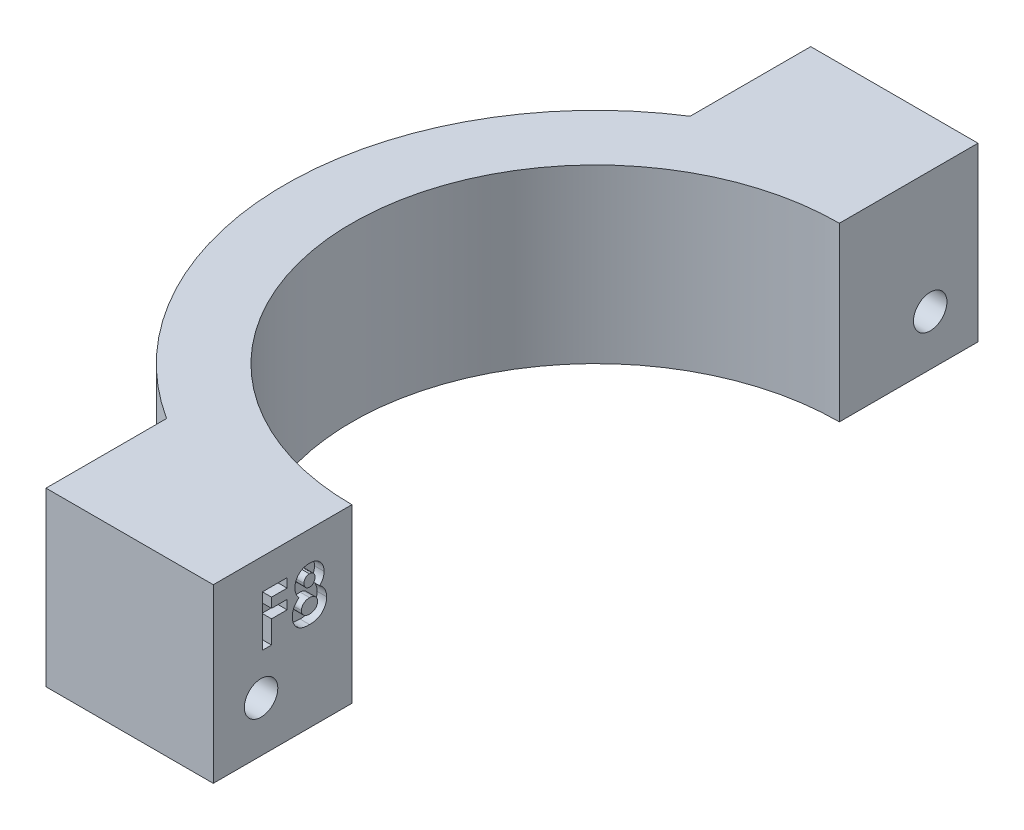
from build123d import *

# Parameters (mm, degrees)
BOSS_EXTRUDE1_DEPTH = 18
SKETCH2_R           = 1.75
CUT_EXTRUDE1_DEPTH  = 33.5
CUT_EXTRUDE2_DEPTH  = 1
CUT_EXTRUDE3_DEPTH  = 5


with BuildPart() as part:
    # Sketch1 → Boss-Extrude1 (new body)
    with BuildSketch(Plane(origin=(0, 0, 0), x_dir=(1, 0, 0), z_dir=(0, 1, 0))):
        with BuildLine():
            Line((-11.998275301, 32.528571429), (-29.498275301, 32.528571429))
            Line((-29.498275301, 32.528571429), (-29.498275301, 19.914699304))
            ThreePointArc((-29.498275301, 19.914699304), (-21.114218589, 23.723916882), (-11.998275301, 25.028571429))
            Line((-11.998275301, 25.028571429), (-11.998275301, 32.528571429))
        make_face()
        with BuildLine():
            ThreePointArc((-11.998275301, 25.028571429), (-21.114218589, 23.723916882), (-29.498275301, 19.914699304))
            ThreePointArc((-29.498275301, 19.914699304), (-44.498275301, -7.471428571), (-29.498275301, -34.857556447))
            ThreePointArc((-29.498275301, -34.857556447), (-21.114218589, -38.666774025), (-11.998275301, -39.971428571))
            Line((-11.998275301, -39.971428571), (-11.998275301, -32.971428571))
            ThreePointArc((-11.998275301, -32.971428571), (-37.498275301, -7.471428571), (-11.998275301, 18.028571429))
            Line((-11.998275301, 18.028571429), (-11.998275301, 25.028571429))
        make_face()
        with BuildLine():
            Line((-29.498275301, -34.857556447), (-29.498275301, -47.471428571))
            Line((-29.498275301, -47.471428571), (-11.998275301, -47.471428571))
            Line((-11.998275301, -47.471428571), (-11.998275301, -39.971428571))
            ThreePointArc((-11.998275301, -39.971428571), (-21.114218589, -38.666774025), (-29.498275301, -34.857556447))
        make_face()
    extrude(amount=BOSS_EXTRUDE1_DEPTH)

    # Sketch2 → Cut-Extrude1 (cut, through all)
    with BuildSketch(Plane(origin=(-11.998275301, 0, 0), x_dir=(0, 0, -1), z_dir=(1, 0, 0))):
        with Locations((-42.471428571, 5.25)):
            Circle(SKETCH2_R)
        with Locations((27.528571429, 5.25)):
            Circle(SKETCH2_R)
    extrude(amount=-CUT_EXTRUDE1_DEPTH, mode=Mode.SUBTRACT)

    # Sketch3 → Cut-Extrude2 (cut)
    with BuildSketch(Plane(origin=(-11.998275301, 0, 0), x_dir=(0, 0, -1), z_dir=(1, 0, 0))):
        Polygon((-42.326802517, 14.778828324), (-39.748811064, 14.778828324), (-39.748811064, 13.829042), (-41.377016192, 13.829042), (-41.377016192, 12.811413795), (-39.748811064, 12.811413795), (-39.748811064, 11.86162747), (-41.377016192, 11.86162747), (-41.377016192, 9.487161658), (-42.326802517, 9.487161658), align=None)
        with BuildLine():
            add(Edge.make_bspline(
                [(-36.335516459, 12.336520632), (-36.280026669, 12.296871678), (-36.170189636, 12.21839015), (-36.025135094, 12.077787559), (-35.900192562, 11.920943738), (-35.796674074, 11.748820735), (-35.713738184, 11.565649379), (-35.65436867, 11.373387552), (-35.616657836, 11.173731052), (-35.612538688, 11.037799338), (-35.610456363, 10.969082731)],
                knots=[0, 0, 0, 0, 0.000204374, 0.00040454, 0.000603696, 0.000804397, 0.00100556, 0.001205386, 0.001406861, 0.001612837, 0.001612837, 0.001612837, 0.001612837], degree=3))
            add(Edge.make_bspline(
                [(-35.610456363, 10.969082731), (-35.612968529, 10.894674741), (-35.617951088, 10.747096043), (-35.662003565, 10.530671904), (-35.732728049, 10.322750724), (-35.829386859, 10.125627426), (-35.950579228, 9.945427847), (-36.091840207, 9.785899867), (-36.253347864, 9.651209834), (-36.403716068, 9.559823515), (-36.533143234, 9.499117311), (-36.637589822, 9.460266559), (-36.747878552, 9.426063908), (-36.864796432, 9.398738259), (-36.988322198, 9.377406106), (-37.118279567, 9.363318392), (-37.254754085, 9.353077482), (-37.347823937, 9.352020083), (-37.39554584, 9.351477897)],
                knots=[0, 0, 0, 0, 0.000223032, 0.000442356, 0.000659577, 0.000880493, 0.001098936, 0.001309154, 0.001517624, 0.001727419, 0.001835068, 0.001946108, 0.002061452, 0.002181268, 0.002306046, 0.002437271, 0.00257329, 0.002716429, 0.002716429, 0.002716429, 0.002716429], degree=3))
            add(Edge.make_bspline(
                [(-37.39554584, 9.351477897), (-37.446436515, 9.352168207), (-37.54581597, 9.353516247), (-37.690887837, 9.361667206), (-37.827733465, 9.376694415), (-37.956639911, 9.396476572), (-38.077483153, 9.422654099), (-38.19026677, 9.455845769), (-38.295263092, 9.493638179), (-38.423784105, 9.551180365), (-38.570660316, 9.641044813), (-38.72940694, 9.772648704), (-38.86874586, 9.929393051), (-38.989887855, 10.106878063), (-39.085376541, 10.304011851), (-39.156384774, 10.514607029), (-39.198436691, 10.73809291), (-39.203499272, 10.89116975), (-39.206076021, 10.969082731)],
                knots=[0, 0, 0, 0, 0.000152677, 0.000298149, 0.000435695, 0.000565531, 0.000689246, 0.000806315, 0.000917981, 0.001023783, 0.001228302, 0.001432294, 0.001640225, 0.001855439, 0.002074937, 0.002295171, 0.002520541, 0.002754154, 0.002754154, 0.002754154, 0.002754154], degree=3))
            add(Edge.make_bspline(
                [(-39.206076021, 10.969082731), (-39.203721304, 11.037048991), (-39.199093999, 11.170610919), (-39.165947986, 11.366321385), (-39.109112646, 11.551878064), (-39.031125713, 11.728572726), (-38.930562888, 11.896425031), (-38.8068295, 12.054199916), (-38.661494363, 12.203320732), (-38.551284013, 12.291384193), (-38.494796307, 12.336520632)],
                knots=[0, 0, 0, 0, 0.000203859, 0.000400608, 0.00059342, 0.000784678, 0.000978652, 0.001178818, 0.001384958, 0.001601707, 0.001601707, 0.001601707, 0.001601707], degree=3))
            add(Edge.make_bspline(
                [(-38.494796307, 12.336520632), (-38.529815688, 12.376910365), (-38.598758303, 12.456425584), (-38.687970725, 12.584398993), (-38.763128433, 12.716339711), (-38.826940906, 12.851176971), (-38.874112713, 12.991232334), (-38.909785473, 13.134303842), (-38.929961952, 13.281849066), (-38.933115597, 13.381298932), (-38.9347085, 13.431530982)],
                knots=[0, 0, 0, 0, 0.000160289, 0.000315561, 0.000467026, 0.000615468, 0.000762297, 0.000909614, 0.001057278, 0.001207985, 0.001207985, 0.001207985, 0.001207985], degree=3))
            add(Edge.make_bspline(
                [(-38.9347085, 13.431530982), (-38.932596552, 13.499530369), (-38.928429761, 13.63369054), (-38.891524733, 13.829864386), (-38.830253425, 14.016268639), (-38.746899026, 14.192357535), (-38.641051892, 14.354293405), (-38.515282582, 14.499513681), (-38.367823027, 14.622699), (-38.204156851, 14.728397441), (-38.023463681, 14.812469001), (-37.827457916, 14.871295982), (-37.618506355, 14.908536563), (-37.474503176, 14.912489943), (-37.400845987, 14.914512085)],
                knots=[0, 0, 0, 0, 0.000203859, 0.000402207, 0.000596296, 0.000791172, 0.000984925, 0.00117499, 0.001365279, 0.001559346, 0.001758058, 0.001960923, 0.002171792, 0.002392586, 0.002392586, 0.002392586, 0.002392586], degree=3))
            add(Edge.make_bspline(
                [(-37.400845987, 14.914512085), (-37.328249653, 14.912486634), (-37.186702004, 14.908537427), (-36.981422486, 14.871543603), (-36.789652445, 14.81140624), (-36.612977675, 14.725559555), (-36.451004125, 14.619657392), (-36.306050757, 14.492182875), (-36.180676115, 14.343345653), (-36.073950383, 14.177220549), (-35.988906375, 13.998244819), (-35.92603364, 13.810551611), (-35.889667308, 13.615616211), (-35.884448814, 13.483264273), (-35.881823885, 13.416690571)],
                knots=[0, 0, 0, 0, 0.000217619, 0.000424311, 0.000623444, 0.000818777, 0.001011644, 0.001202408, 0.001395686, 0.001593574, 0.001793189, 0.001988617, 0.002185922, 0.002385613, 0.002385613, 0.002385613, 0.002385613], degree=3))
            add(Edge.make_bspline(
                [(-35.881823885, 13.416690571), (-35.883088376, 13.369639878), (-35.885569846, 13.277306412), (-35.903917335, 13.141273159), (-35.934812254, 13.010749069), (-35.977886766, 12.882579913), (-36.037775043, 12.75328262), (-36.118817806, 12.620379619), (-36.217395685, 12.478348765), (-36.294813818, 12.385392472), (-36.335516459, 12.336520632)],
                knots=[0, 0, 0, 0, 0.000141127, 0.000276952, 0.00041091, 0.000542985, 0.00068195, 0.000837384, 0.001009416, 0.00120013, 0.00120013, 0.00120013, 0.00120013], degree=3))
        make_face()
        with BuildLine():
            add(Edge.make_bspline(
                [(-37.424166633, 13.96472576), (-37.463271319, 13.962840553), (-37.539338574, 13.959173407), (-37.64787764, 13.926073356), (-37.745457801, 13.871935869), (-37.829851598, 13.797432033), (-37.899058911, 13.707032789), (-37.949922483, 13.603100385), (-37.980085183, 13.486917464), (-37.983278492, 13.40556398), (-37.984922175, 13.363689102)],
                knots=[0, 0, 0, 0, 0.000117084, 0.000227754, 0.000336891, 0.000449574, 0.000563002, 0.000676306, 0.000794574, 0.000920021, 0.000920021, 0.000920021, 0.000920021], degree=3))
            add(Edge.make_bspline(
                [(-37.984922175, 13.363689102), (-37.982891723, 13.321456603), (-37.97892707, 13.238993579), (-37.947749526, 13.120578406), (-37.894606542, 13.013260584), (-37.821641583, 12.91928163), (-37.732977342, 12.842522339), (-37.633700572, 12.783897865), (-37.522710277, 12.750430672), (-37.445582672, 12.745892402), (-37.406146134, 12.743571914)],
                knots=[0, 0, 0, 0, 0.000126588, 0.000247175, 0.000364269, 0.000483644, 0.000601612, 0.00071416, 0.000827166, 0.000945406, 0.000945406, 0.000945406, 0.000945406], degree=3))
            add(Edge.make_bspline(
                [(-37.406146134, 12.743571914), (-37.365964026, 12.745369894), (-37.287681743, 12.748872697), (-37.176414319, 12.78320827), (-37.07617659, 12.83812102), (-36.990337784, 12.915755501), (-36.919236884, 13.009768489), (-36.86745574, 13.118961784), (-36.837652384, 13.241283785), (-36.833673531, 13.326775634), (-36.831610209, 13.371109307)],
                knots=[0, 0, 0, 0, 0.000120251, 0.000234272, 0.000345777, 0.000460657, 0.000578745, 0.000697283, 0.000820689, 0.000953616, 0.000953616, 0.000953616, 0.000953616], degree=3))
            add(Edge.make_bspline(
                [(-36.831610209, 13.371109307), (-36.833725725, 13.412956504), (-36.837817057, 13.493887511), (-36.867153475, 13.61007797), (-36.921031274, 13.712388236), (-36.991819752, 13.80222612), (-37.080569531, 13.874674785), (-37.183601525, 13.92795397), (-37.300157048, 13.958856413), (-37.381934959, 13.962726944), (-37.424166633, 13.96472576)],
                knots=[0, 0, 0, 0, 0.000125532, 0.000242774, 0.000356083, 0.000469981, 0.000583721, 0.00069703, 0.000815568, 0.000942157, 0.000942157, 0.000942157, 0.000942157], degree=3))
        make_face(mode=Mode.SUBTRACT)
        with BuildLine():
            add(Edge.make_bspline(
                [(-37.393425781, 11.793785589), (-37.423142383, 11.793292101), (-37.481713433, 11.792319441), (-37.56781769, 11.781103218), (-37.650443574, 11.764388271), (-37.729488574, 11.741330474), (-37.804553359, 11.709896893), (-37.876274229, 11.672003131), (-37.944403494, 11.627266129), (-38.007930605, 11.576498088), (-38.065344269, 11.520775326), (-38.117097464, 11.462658291), (-38.159398394, 11.400644502), (-38.194624984, 11.336795315), (-38.222929748, 11.270604761), (-38.241641337, 11.200982818), (-38.25368898, 11.128856654), (-38.255417691, 11.079727236), (-38.256289697, 11.054945111)],
                knots=[0, 0, 0, 0, 8.9099e-05, 0.000175613, 0.000260017, 0.000341853, 0.000422171, 0.000503731, 0.000584877, 0.000666327, 0.000747292, 0.000824675, 0.00089936, 0.000971947, 0.001043213, 0.001114708, 0.001187727, 0.00126205, 0.00126205, 0.00126205, 0.00126205], degree=3))
            add(Edge.make_bspline(
                [(-38.256289697, 11.054945111), (-38.255874083, 11.029099803), (-38.255049766, 10.977838831), (-38.242599604, 10.903019303), (-38.22467357, 10.830861005), (-38.199495883, 10.762039385), (-38.16582551, 10.696594509), (-38.125622473, 10.633890112), (-38.07748491, 10.574365887), (-38.022718053, 10.518340983), (-37.9614068, 10.467796519), (-37.895326706, 10.423265965), (-37.825350538, 10.38400555), (-37.74937766, 10.355728644), (-37.670221653, 10.329847135), (-37.585761901, 10.314145446), (-37.496920893, 10.302591708), (-37.436222334, 10.301714301), (-37.405086104, 10.301264222)],
                knots=[0, 0, 0, 0, 7.7447e-05, 0.000153607, 0.00022688, 0.000300329, 0.000372861, 0.000447252, 0.000523405, 0.000602112, 0.000681917, 0.000761299, 0.000840992, 0.000921895, 0.001004039, 0.001090521, 0.001179139, 0.001272476, 0.001272476, 0.001272476, 0.001272476], degree=3))
            add(Edge.make_bspline(
                [(-37.405086104, 10.301264222), (-37.373612008, 10.301834727), (-37.312278962, 10.302946461), (-37.222622382, 10.312772086), (-37.13782317, 10.328362495), (-37.057982614, 10.350660411), (-36.982798794, 10.37922493), (-36.913280238, 10.415581909), (-36.847839721, 10.456784484), (-36.788580182, 10.504921414), (-36.734471854, 10.557380621), (-36.687849933, 10.61487145), (-36.64820783, 10.675545204), (-36.616232154, 10.740057463), (-36.590430656, 10.808103704), (-36.572732447, 10.880362419), (-36.561750071, 10.956021588), (-36.560750544, 11.007558733), (-36.560242688, 11.033744524)],
                knots=[0, 0, 0, 0, 9.4396e-05, 0.000183948, 0.000270228, 0.000352788, 0.000432319, 0.000511018, 0.000587766, 0.000663919, 0.000739628, 0.000813465, 0.0008855, 0.000956609, 0.001029065, 0.001103365, 0.00117937, 0.001257877, 0.001257877, 0.001257877, 0.001257877], degree=3))
            add(Edge.make_bspline(
                [(-36.560242688, 11.033744524), (-36.561212393, 11.060272656), (-36.563107829, 11.112125961), (-36.573479379, 11.188699562), (-36.592935347, 11.261292533), (-36.618389437, 11.331588487), (-36.652249222, 11.398132766), (-36.694285411, 11.46078493), (-36.742132913, 11.521096946), (-36.798056071, 11.576383943), (-36.859199348, 11.626935909), (-36.924276621, 11.671972162), (-36.993087444, 11.710113715), (-37.065820037, 11.741292539), (-37.142740149, 11.764400269), (-37.223260876, 11.781102631), (-37.307250134, 11.792321952), (-37.364414838, 11.793292857), (-37.393425781, 11.793785589)],
                knots=[0, 0, 0, 0, 7.9615e-05, 0.00015562, 0.00023121, 0.000304659, 0.000379561, 0.000454532, 0.000530684, 0.000610137, 0.000689943, 0.000768449, 0.000847213, 0.000925576, 0.001005382, 0.00108771, 0.001172121, 0.001259101, 0.001259101, 0.001259101, 0.001259101], degree=3))
        make_face(mode=Mode.SUBTRACT)
    extrude(amount=-CUT_EXTRUDE2_DEPTH, mode=Mode.SUBTRACT)

    # Sketch4 → Cut-Extrude3 (cut)
    with BuildSketch(Plane.ZY.offset(29.498275301)):
        Polygon((-25.391799088, 2.901056132), (-24.425940196, 5.926027195), (-26.562712537, 8.274971063), (-29.665343769, 7.598943868), (-30.631202661, 4.573972805), (-28.49443032, 2.225028937), align=None)
        Polygon((44.716794169, 3.004634402), (45.538655018, 6.071860849), (43.293289421, 8.317226447), (40.226062974, 7.495365598), (39.404202124, 4.428139151), (41.649567722, 2.182773553), align=None)
    extrude(amount=-CUT_EXTRUDE3_DEPTH, mode=Mode.SUBTRACT)


solid = part.part
